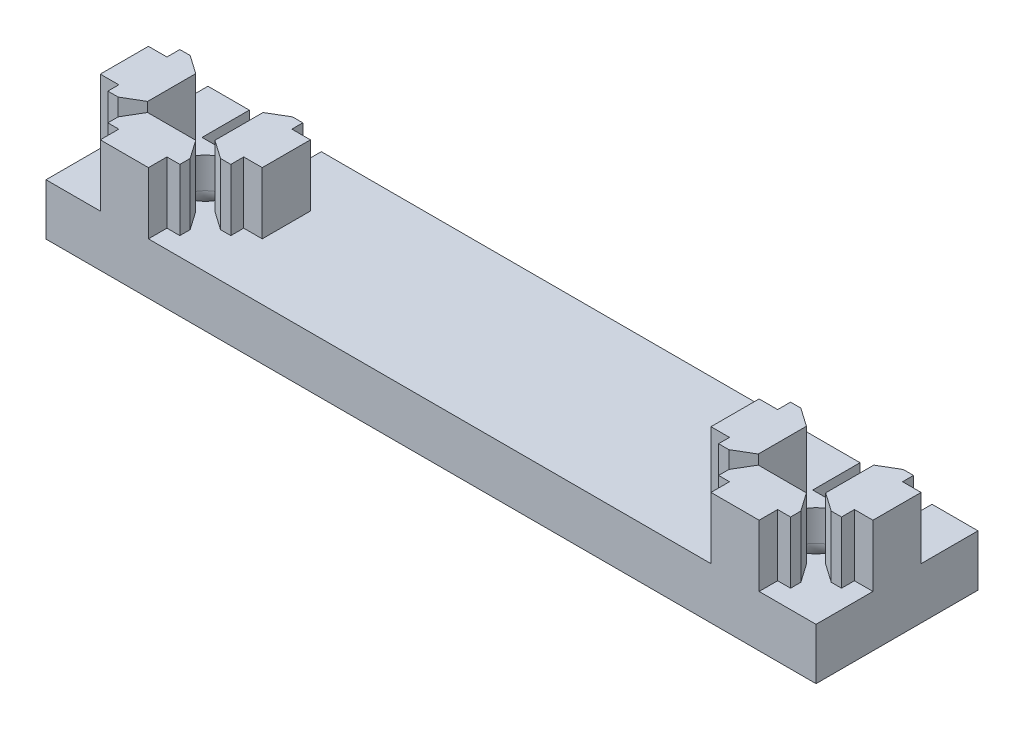
from build123d import *

# Parameters (mm, degrees)
BOSS_EXTRUDE1_DEPTH   = 7.62
BOSS_EXTRUDE1_2_DEPTH = 7.62
BOSS_EXTRUDE1_3_DEPTH = 7.62
BOSS_EXTRUDE1_4_DEPTH = 7.62
SKETCH2_W             = 132.9538108
SKETCH2_H             = 20
BOSS_EXTRUDE2_DEPTH   = 6.35
LPATTERN2_COUNT       = 2
LPATTERN2_PITCH       = 75.4126
CUT_EXTRUDE1_DEPTH    = 125.148300392
FILLET1_R             = 2.54
SKETCH13_R            = 3.5
CUT_EXTRUDE5_DEPTH    = 124.59491895
FILLET6_R             = 2.54
SKETCH14_W            = 8.89
SKETCH14_H            = 5.842
CUT_EXTRUDE6_DEPTH    = 125.148300392
SKETCH15_W            = 25.4
SKETCH15_H            = 40.894
BOSS_EXTRUDE3_DEPTH   = 12.7
FILLET15_R            = 10.16
FILLET16_R            = 10.16
FILLET17_R            = 10.16
FILLET18_R            = 10.16
SKETCH18_R            = 1.984375
CUT_EXTRUDE9_DEPTH    = 12.7
SKETCH19_W            = 37.866917971
SKETCH19_H            = 35.1892
CUT_EXTRUDE10_DEPTH   = 133.001722138


with BuildPart() as part:
    # Sketch1 → Boss-Extrude1 (new body)
    with BuildSketch(Plane(origin=(0, 0, 0), x_dir=(1, 0, 0), z_dir=(0, 1, 0))):
        Polygon((2.9718, 10), (-2.9718, 10), (-2.9718, 7.714), (-4.567901235, 7.714), (-4.567901235, 6.444), (-2.9718, 4.158), (2.9718, 4.158), (4.322098765, 6.444), (4.322098765, 7.714), (2.9718, 7.714), align=None)
    boss_extrude1 = extrude(amount=BOSS_EXTRUDE1_DEPTH)



with BuildPart() as body_2:
    # Sketch1 → Boss-Extrude1 2 (new body)
    with BuildSketch(Plane(origin=(0, 0, 0), x_dir=(1, 0, 0), z_dir=(0, 1, 0))):
        Polygon((4.158, -2.9718), (4.158, 2.9718), (6.444, 4.322098765), (7.714, 4.322098765), (7.714, 2.9718), (10, 2.9718), (10, -2.9718), (7.714, -2.9718), (7.714, -4.567901235), (6.444, -4.567901235), align=None)
    boss_extrude1_2 = extrude(amount=BOSS_EXTRUDE1_2_DEPTH)


with BuildPart() as body_3:
    # Sketch1 → Boss-Extrude1 3 (new body)
    with BuildSketch(Plane(origin=(0, 0, 0), x_dir=(1, 0, 0), z_dir=(0, 1, 0))):
        Polygon((-10, -2.9718), (-10, 2.9718), (-7.714, 2.9718), (-7.714, 4.567901235), (-6.444, 4.567901235), (-4.158, 2.9718), (-4.158, -2.9718), (-6.444, -4.322098765), (-7.714, -4.322098765), (-7.714, -2.9718), align=None)
    boss_extrude1_3 = extrude(amount=BOSS_EXTRUDE1_3_DEPTH)


with BuildPart() as body_4:
    # Sketch1 → Boss-Extrude1 4 (new body)
    with BuildSketch(Plane(origin=(0, 0, 0), x_dir=(1, 0, 0), z_dir=(0, 1, 0))):
        Polygon((4.567901235, -6.444), (2.9718, -4.158), (-2.9718, -4.158), (-4.322098765, -6.444), (-4.322098765, -7.714), (-2.9718, -7.714), (-2.9718, -10), (2.9718, -10), (2.9718, -7.714), (4.567901235, -7.714), align=None)
    boss_extrude1_4 = extrude(amount=BOSS_EXTRUDE1_4_DEPTH)


with BuildPart() as part_1:
    add(part.part)

    add(body_2.part)  # Boss-Extrude2 merges body 2

    add(body_3.part)  # Boss-Extrude2 merges body 3

    add(body_4.part)  # Boss-Extrude2 merges body 4
    # Sketch2 → Boss-Extrude2 (add)
    with BuildSketch(Plane.XZ):
        with Locations((-56.4769054, 0)):
            Rectangle(SKETCH2_W, SKETCH2_H)
    extrude(amount=BOSS_EXTRUDE2_DEPTH)

    # LPattern2: Boss-Extrude1, Boss-Extrude1 2, Boss-Extrude1 3, Boss-Extrude1 4 ×2
    with Locations(*[(-i * LPATTERN2_PITCH, 0, 0) for i in range(1, LPATTERN2_COUNT)]):
        add(boss_extrude1)
        add(boss_extrude1_2)
        add(boss_extrude1_3)
        add(boss_extrude1_4)

    # Sketch4 → Cut-Extrude1 (cut, through all)
    with BuildSketch(Plane(origin=(0, -6.35, 0), x_dir=(-1, 0, 0), z_dir=(0, -1, 0))):
        Polygon((122.9538108, -10), (85.4126108, -10), (122.9538108, -0.2108), align=None)
    extrude(amount=-CUT_EXTRUDE1_DEPTH, mode=Mode.SUBTRACT)

    # Fillet1
    fillet1_edges = [part_1.edges().sort_by_distance(p)[0] for p in [
        (-85.4126108, -3.175, 10),
    ]]
    fillet(fillet1_edges, radius=FILLET1_R)

    # Sketch13 → Cut-Extrude5 (cut, through all)
    with BuildSketch(Plane(origin=(0, 0, 0), x_dir=(1, 0, 0), z_dir=(0, 1, 0))):
        with Locations(Location((0, 0, 0), (0, 0, 270))):
            Circle(SKETCH13_R)
        with Locations(Location((-75.4126, 0, 0), (0, 0, 270))):
            Circle(SKETCH13_R)
    extrude(amount=-CUT_EXTRUDE5_DEPTH, mode=Mode.SUBTRACT)

    # Fillet6
    fillet6_edges = [part_1.edges().sort_by_distance(p)[0] for p in [
        (0, -6.35, -3.5),
        (-75.4126, -6.35, -3.5),
    ]]
    fillet(fillet6_edges, radius=FILLET6_R)

    # Sketch14 → Cut-Extrude6 (cut, through all)
    with BuildSketch(Plane(origin=(0, 7.62, 0), x_dir=(1, 0, 0), z_dir=(0, 1, 0))):
        with Locations((-0.122901235, 7.079)):
            Rectangle(SKETCH14_W, SKETCH14_H)
        with Locations((-75.535501235, 7.079)):
            Rectangle(SKETCH14_W, SKETCH14_H)
    extrude(amount=-CUT_EXTRUDE6_DEPTH, mode=Mode.SUBTRACT)

    # Sketch15 → Boss-Extrude3 (add)
    with BuildSketch(Plane.ZY.offset(122.9538108)):
        with Locations((-12.4892, -20.447)):
            Rectangle(SKETCH15_W, SKETCH15_H)
    extrude(amount=-BOSS_EXTRUDE3_DEPTH)

    # Fillet15
    fillet15_edges = [part_1.edges().sort_by_distance(p)[0] for p in [
        (-110.2538108, -6.35, -4.8946),
    ]]
    fillet(fillet15_edges, radius=FILLET15_R)

    # Fillet16
    fillet16_edges = [part_1.edges().sort_by_distance(p)[0] for p in [
        (-110.2538108, -8.255, -10),
    ]]
    fillet(fillet16_edges, radius=FILLET16_R)

    # Fillet17
    fillet17_edges = [part_1.edges().sort_by_distance(p)[0] for p in [
        (-110.2538108, -40.894, -12.4892),
    ]]
    fillet(fillet17_edges, radius=FILLET17_R)

    # Fillet18
    fillet18_edges = [part_1.edges().sort_by_distance(p)[0] for p in [
        (-107.278015697, -9.325795103, 0.2108),
        (-121.6838108, -40.894, 0.2108),
        (-110.2538108, -23.622, 0.2108),
        (-113.229605903, -37.918204897, 0.2108),
    ]]
    fillet(fillet18_edges, radius=FILLET18_R)

    # Sketch18 → Cut-Extrude9 (cut)
    with BuildSketch(Plane.ZY.offset(122.9538108)):
        with Locations((-12.4892, -28.194)):
            Circle(SKETCH18_R)
    extrude(amount=-CUT_EXTRUDE9_DEPTH, mode=Mode.SUBTRACT)

    # Sketch19 → Cut-Extrude10 (cut, through all)
    with BuildSketch(Plane(origin=(0, 0, 0), x_dir=(1, 0, 0), z_dir=(0, 1, 0))):
        with Locations((-104.020351815, 7.5946)):
            Rectangle(SKETCH19_W, SKETCH19_H)
    extrude(amount=-CUT_EXTRUDE10_DEPTH, mode=Mode.SUBTRACT)


solid = part_1.part
